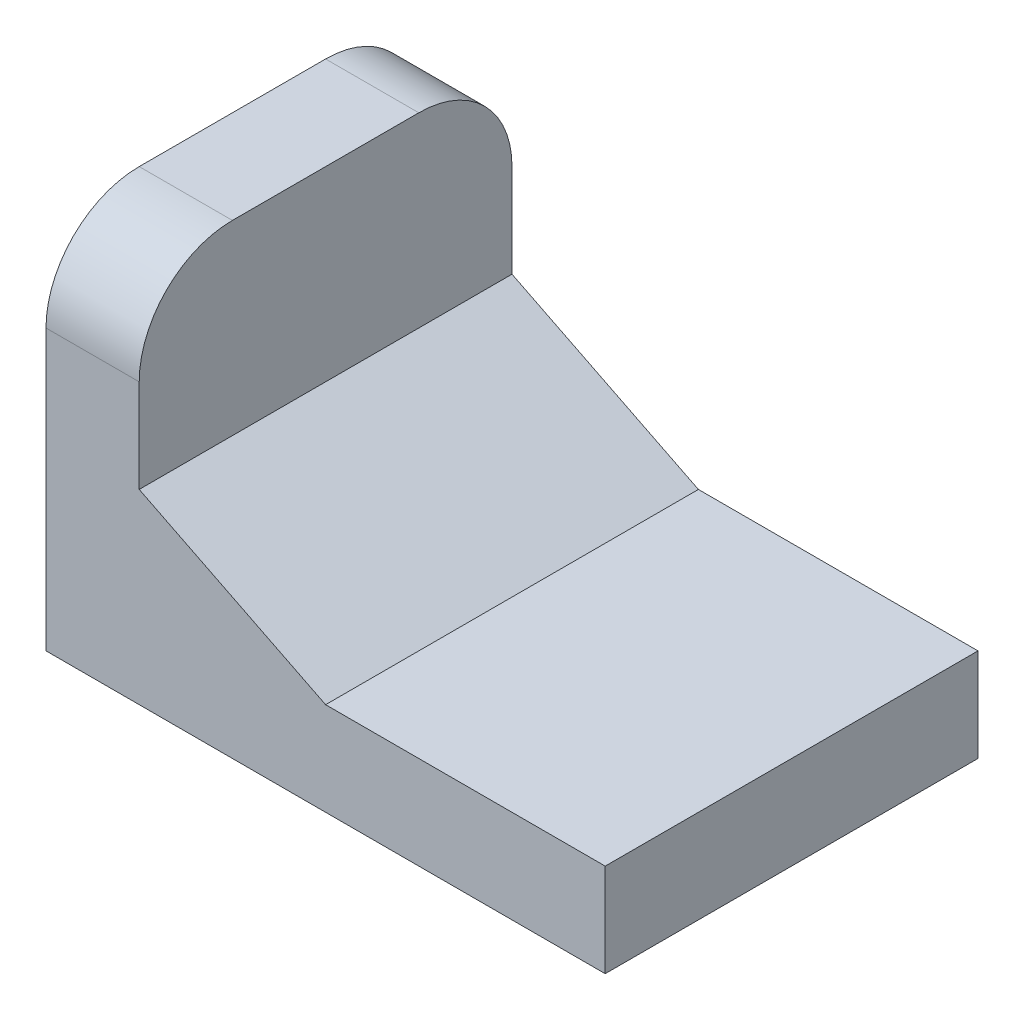
from build123d import *

# Parameters (mm, degrees)
EXTRUDE_1_DEPTH = 20
FILLET_1_R      = 5


with BuildPart() as part:
    # 草圖1 → 填料-伸長1 (new body)
    with BuildSketch(Plane.XY):
        Polygon((30, 5), (15, 5), (5, 10), (5, 20), (0, 20), (0, 5), (0, 0), (5, 0), (30, 0), align=None)
    extrude(amount=EXTRUDE_1_DEPTH)

    # 圓角1
    fillet_1_edges = [part.edges().sort_by_distance(p)[0] for p in [
        (2.5, 20, 20),
        (2.5, 20, 0),
    ]]
    fillet(fillet_1_edges, radius=FILLET_1_R)


solid = part.part
